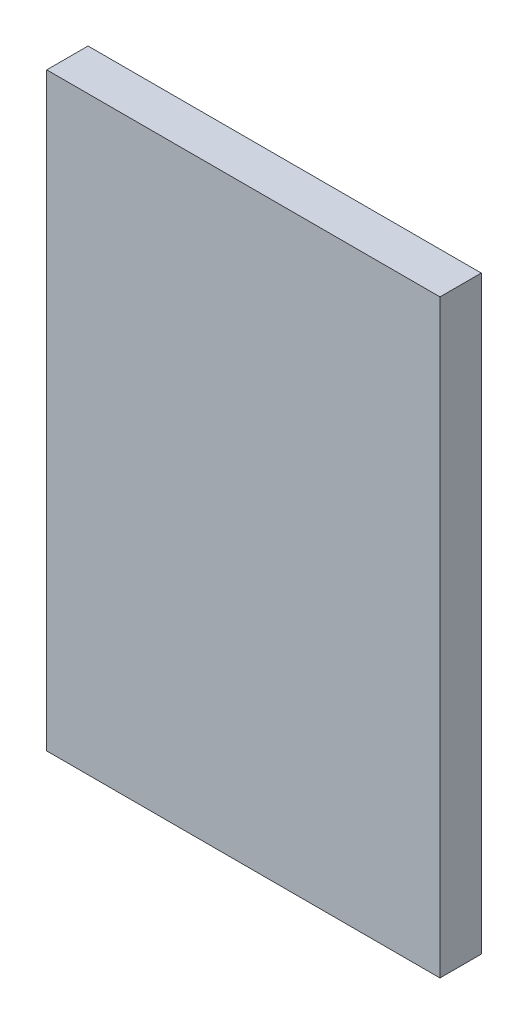
from build123d import *

# Parameters (mm, degrees)
SKETCH1_W           = 200
SKETCH1_H           = 300
BOSS_EXTRUDE1_DEPTH = 21


with BuildPart() as part:
    # Sketch1 → Boss-Extrude1 (new body)
    with BuildSketch(Plane.XY):
        with Locations((100, 150)):
            Rectangle(SKETCH1_W, SKETCH1_H)
    extrude(amount=BOSS_EXTRUDE1_DEPTH)


solid = part.part
